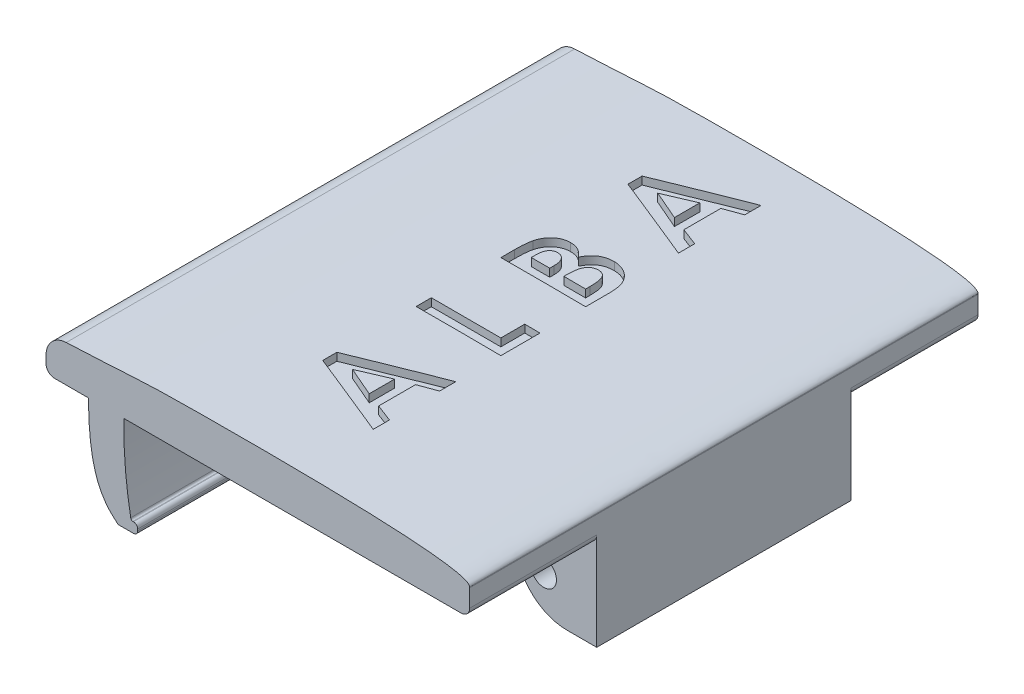
from build123d import *

# Parameters (mm, degrees)
BOSS_EXTRUDE1_DEPTH      = 12
SKETCH2_W                = 1.9
SKETCH2_H                = 6
BOSS_EXTRUDE2_DEPTH      = 2.1
BOSS_EXTRUDE2_DEPTH_BACK = 0.3
FILLET1_R                = 1.2
SKETCH3_R                = 0.3
CUT_EXTRUDE1_DEPTH       = 10.0000001
CUT_EXTRUDE3_DEPTH       = 0.3


with BuildPart() as part:
    # Sketch1 → Boss-Extrude1 (new body)
    with BuildSketch(Plane.XY):
        with BuildLine():
            Line((3.095772213, 5.384528852), (3.895772213, 5.384528852))
            add(Edge.make_bspline(
                [(3.895772213, 5.384528852), (3.903661021, 4.876234197), (3.940780884, 4.342027393), (4.23358721, 3.366561313), (4.591998935, 3.174137137), (4.595359051, 3.146585866)],
                knots=[0, 0, 0, 0, 0.345637442, 0.444282907, 0.986454656, 0.986454656, 0.986454656, 0.986454656], degree=3))
            Line((4.595359051, 3.146585866), (4.95987534, 3.146585866))
            ThreePointArc((4.95987534, 3.146585866), (5.030586018, 3.175875188), (5.05987534, 3.246585866))
            Line((5.05987534, 3.246585866), (5.05987534, 3.284528852))
            ThreePointArc((5.05987534, 3.284528852), (5.030586018, 3.35523953), (4.95987534, 3.384528852))
            Line((4.95987534, 3.384528852), (4.945772213, 3.384528852))
            ThreePointArc((4.945772213, 3.384528852), (4.910416874, 3.399173513), (4.895772213, 3.434528852))
            add(Edge.make_bspline(
                [(4.895772213, 3.434528852), (4.718180189, 4.396675532), (4.732797844, 5.384528852)],
                knots=[0, 0, 0, 1, 1, 1], degree=2))
            Line((4.732797844, 5.384528852), (4.895772213, 5.384528852))
            Line((4.895772213, 5.384528852), (12.695772213, 5.384528852))
            ThreePointArc((12.695772213, 5.384528852), (12.83719357, 5.443107495), (12.895772213, 5.584528852))
            Line((12.895772213, 5.584528852), (12.895772213, 6.001862294))
            ThreePointArc((12.895772213, 6.001862294), (12.895689546, 6.010954061), (12.895441572, 6.020042821))
            add(Edge.make_bspline(
                [(12.895441572, 6.020042821), (12.882423834, 6.377819315), (4.452086176, 6.40842871), (5.31917207, 6.339679785), (3.374260508, 6.255925505)],
                knots=[0.048294157, 0.048294157, 0.048294157, 0.048294157, 0.480381526, 0.960763051, 0.960763051, 0.960763051, 0.960763051], degree=3))
            ThreePointArc((3.374260508, 6.255925505), (3.034693377, 6.102252714), (2.895772213, 5.756388473))
            Line((2.895772213, 5.756388473), (2.895772213, 5.584528852))
            ThreePointArc((2.895772213, 5.584528852), (2.954350857, 5.443107495), (3.095772213, 5.384528852))
        make_face()
    extrude(amount=BOSS_EXTRUDE1_DEPTH)

    # Sketch2 → Boss-Extrude2 (add, two sides)
    with BuildSketch(Plane.XZ.offset(-5.384528852)) as boss_extrude2_sk:
        with Locations((11.945772213, 6)):
            Rectangle(SKETCH2_W, SKETCH2_H)
    extrude(amount=BOSS_EXTRUDE2_DEPTH)
    extrude(boss_extrude2_sk.sketch, amount=-BOSS_EXTRUDE2_DEPTH_BACK)

    # Fillet1
    fillet1_edges = [part.edges().sort_by_distance(p)[0] for p in [
        (10.995772213, 3.284528852, 6),
    ]]
    fillet(fillet1_edges, radius=FILLET1_R)

    # Sketch3 → Cut-Extrude1 (cut, through all)
    with BuildSketch(Plane.XY.offset(9)):
        with Locations((11.645772213, 4.184528852)):
            Circle(SKETCH3_R)
    extrude(amount=-CUT_EXTRUDE1_DEPTH, mode=Mode.SUBTRACT)

    # Sketch9 → Cut-Extrude3 (cut)
    with BuildSketch(Plane(origin=(0, 6.5, 0), x_dir=(-1, 0, 0), z_dir=(0, 1, 0))):
        Polygon((-6.895772213, 9.467821607), (-6.895772213, 9.134888915), (-8.895772213, 8.327196607), (-8.895772213, 8.710610069), (-8.485515803, 8.866058787), (-8.485515803, 9.737453018), (-8.895772213, 9.892901736), (-8.895772213, 10.275914556), align=None)
        Polygon((-7.432230547, 9.301555582), (-8.126541444, 9.601235069), (-8.126541444, 9.001876094), align=None, mode=Mode.SUBTRACT)
        Polygon((-6.895772213, 7.263094043), (-6.895772213, 6.904119684), (-8.536797854, 6.904119684), (-8.536797854, 6.34001712), (-8.895772213, 6.34001712), (-8.895772213, 7.263094043), align=None)
        with BuildLine():
            Line((-8.895772213, 5.263094043), (-6.895772213, 5.263094043))
            Line((-6.895772213, 5.263094043), (-6.895772213, 4.942581223))
            add(Edge.make_bspline(
                [(-6.895772213, 4.942581223), (-6.89576915, 4.920143281), (-6.895763223, 4.87672629), (-6.897969651, 4.81408755), (-6.900785983, 4.756126181), (-6.904042621, 4.702771449), (-6.909447398, 4.654043105), (-6.915263959, 4.609907591), (-6.922232029, 4.57052837), (-6.928486646, 4.546182634), (-6.931429265, 4.534728659)],
                knots=[0, 0, 0, 0, 6.7309e-05, 0.000130241, 0.000188002, 0.000241409, 0.000290564, 0.000335042, 0.000374962, 0.000410429, 0.000410429, 0.000410429, 0.000410429], degree=3))
            add(Edge.make_bspline(
                [(-6.931429265, 4.534728659), (-6.935579572, 4.519688397), (-6.943723806, 4.490174574), (-6.960171441, 4.447901364), (-6.97845415, 4.407799319), (-6.999311312, 4.36991744), (-7.022994683, 4.334488204), (-7.049692405, 4.301646744), (-7.078332148, 4.270682921), (-7.109714666, 4.242702918), (-7.142868572, 4.21739431), (-7.177819973, 4.195475979), (-7.213863307, 4.176197015), (-7.252000271, 4.161690241), (-7.29110813, 4.149383507), (-7.331937707, 4.141170522), (-7.374119089, 4.135654208), (-7.402831856, 4.135146589), (-7.417406829, 4.134888915)],
                knots=[0, 0, 0, 0, 4.6779e-05, 9.1795e-05, 0.000135895, 0.000178934, 0.000221381, 0.000263553, 0.000305788, 0.000347777, 0.000389524, 0.000430761, 0.00047144, 0.000511912, 0.000552974, 0.000594304, 0.000636692, 0.000680391, 0.000680391, 0.000680391, 0.000680391], degree=3))
            add(Edge.make_bspline(
                [(-7.417406829, 4.134888915), (-7.436140995, 4.135516162), (-7.473039023, 4.136751561), (-7.526999828, 4.146177564), (-7.578340947, 4.161543583), (-7.627551564, 4.182729904), (-7.674067743, 4.212006743), (-7.719345219, 4.247868191), (-7.762594053, 4.29196921), (-7.789098826, 4.325208854), (-7.802823495, 4.342420966)],
                knots=[0, 0, 0, 0, 5.6181e-05, 0.000110652, 0.000163762, 0.000216687, 0.000270834, 0.000328148, 0.000389624, 0.000455643, 0.000455643, 0.000455643, 0.000455643], degree=3))
            add(Edge.make_bspline(
                [(-7.802823495, 4.342420966), (-7.810021176, 4.328319243), (-7.824133835, 4.300669664), (-7.847343971, 4.261427485), (-7.871981315, 4.225048044), (-7.897833244, 4.191500729), (-7.925088509, 4.160902705), (-7.953875939, 4.133452902), (-7.983697761, 4.108578783), (-8.015161631, 4.086873499), (-8.047889868, 4.067949776), (-8.08193808, 4.051333271), (-8.117790231, 4.038024751), (-8.154686247, 4.026084094), (-8.193174336, 4.017333889), (-8.233120199, 4.011587026), (-8.274415685, 4.007199715), (-8.302544066, 4.006857689), (-8.316845931, 4.006683787)],
                knots=[0, 0, 0, 0, 4.7489e-05, 9.3113e-05, 0.000136672, 0.000179225, 0.000220083, 0.00025947, 0.000298456, 0.000336464, 0.000373983, 0.000411793, 0.000449963, 0.00048861, 0.000528068, 0.000568185, 0.000609645, 0.00065253, 0.00065253, 0.00065253, 0.00065253], degree=3))
            add(Edge.make_bspline(
                [(-8.316845931, 4.006683787), (-8.344175238, 4.007754958), (-8.398136694, 4.009869976), (-8.477072524, 4.026942267), (-8.552356588, 4.054339784), (-8.622879164, 4.092388221), (-8.687074775, 4.138980081), (-8.743313015, 4.192611572), (-8.790760662, 4.252634119), (-8.823070628, 4.307807267), (-8.844649453, 4.355757941), (-8.857809881, 4.395653107), (-8.8702541, 4.438396592), (-8.878905669, 4.484764398), (-8.886846605, 4.534002315), (-8.891744652, 4.586600667), (-8.895065437, 4.642458166), (-8.895531858, 4.680823635), (-8.895772213, 4.700594043)],
                knots=[0, 0, 0, 0, 8.1923e-05, 0.000161756, 0.000241099, 0.000321581, 0.000401318, 0.000478393, 0.000553979, 0.000630113, 0.000669572, 0.000711509, 0.000756031, 0.000803017, 0.00085288, 0.000905622, 0.000961403, 0.00102071, 0.00102071, 0.00102071, 0.00102071], degree=3))
            Line((-8.895772213, 4.700594043), (-8.895772213, 5.263094043))
        make_face()
        with BuildLine():
            Line((-7.254746572, 4.904119684), (-7.690644008, 4.904119684))
            Line((-7.690644008, 4.904119684), (-7.690644008, 4.80876712))
            add(Edge.make_bspline(
                [(-7.690644008, 4.80876712), (-7.690531513, 4.795807689), (-7.690314349, 4.770790292), (-7.687497647, 4.734657918), (-7.682727609, 4.701051252), (-7.675931061, 4.670014756), (-7.667695348, 4.64136713), (-7.657220309, 4.615447658), (-7.644721948, 4.592172173), (-7.626558815, 4.564747939), (-7.598744213, 4.536499336), (-7.559481892, 4.511204214), (-7.514037172, 4.496379474), (-7.48201799, 4.494720133), (-7.465483752, 4.493863274)],
                knots=[0, 0, 0, 0, 3.887e-05, 7.5037e-05, 0.000108636, 0.00014062, 0.000170283, 0.000197959, 0.000224307, 0.00024942, 0.000296451, 0.00034202, 0.000388391, 0.000437904, 0.000437904, 0.000437904, 0.000437904], degree=3))
            add(Edge.make_bspline(
                [(-7.465483752, 4.493863274), (-7.449995905, 4.494548676), (-7.420050777, 4.495873872), (-7.377975761, 4.510810639), (-7.340885044, 4.534079984), (-7.315125093, 4.561135675), (-7.297824625, 4.586940802), (-7.286230763, 4.609137003), (-7.276163259, 4.633633565), (-7.268199209, 4.660625987), (-7.262331286, 4.690016742), (-7.257998188, 4.721726971), (-7.255055537, 4.75582756), (-7.25485177, 4.779380218), (-7.254746572, 4.791539556)],
                knots=[0, 0, 0, 0, 4.6284e-05, 8.9488e-05, 0.000132169, 0.000176655, 0.000200323, 0.000225234, 0.000251646, 0.000279659, 0.000309517, 0.000341473, 0.000375643, 0.00041211, 0.00041211, 0.00041211, 0.00041211], degree=3))
            Line((-7.254746572, 4.791539556), (-7.254746572, 4.904119684))
        make_face(mode=Mode.SUBTRACT)
        with BuildLine():
            Line((-8.023977342, 4.904119684), (-8.536797854, 4.904119684))
            Line((-8.536797854, 4.904119684), (-8.536797854, 4.8007543))
            add(Edge.make_bspline(
                [(-8.536797854, 4.8007543), (-8.536681107, 4.780318831), (-8.536456646, 4.741029094), (-8.533744626, 4.684746615), (-8.528856687, 4.63357177), (-8.522754489, 4.587640155), (-8.514486966, 4.546881415), (-8.503975869, 4.511433326), (-8.492411831, 4.480809763), (-8.478128872, 4.455194346), (-8.46150705, 4.434268018), (-8.444519148, 4.415384201), (-8.424921998, 4.399987513), (-8.403556851, 4.387805366), (-8.380954434, 4.37726174), (-8.356232129, 4.370902569), (-8.330122648, 4.366060919), (-8.312063284, 4.36579447), (-8.302823495, 4.365658146)],
                knots=[0, 0, 0, 0, 6.1303e-05, 0.000117863, 0.000168971, 0.000215489, 0.000256819, 0.000293582, 0.000326317, 0.000354842, 0.000381126, 0.000406353, 0.000430881, 0.00045548, 0.00048005, 0.000505421, 0.000531833, 0.000559503, 0.000559503, 0.000559503, 0.000559503], degree=3))
            add(Edge.make_bspline(
                [(-8.302823495, 4.365658146), (-8.29225762, 4.365958748), (-8.271678136, 4.366544241), (-8.24159957, 4.37132692), (-8.213517158, 4.38001618), (-8.186722614, 4.390968682), (-8.16213939, 4.406179435), (-8.139129249, 4.424308884), (-8.11784783, 4.445768011), (-8.097931884, 4.470400026), (-8.080187567, 4.499138013), (-8.065148812, 4.532180137), (-8.052273288, 4.569335463), (-8.042150222, 4.610831054), (-8.033528004, 4.656527697), (-8.028386934, 4.706780851), (-8.024560725, 4.761165356), (-8.024176221, 4.798876751), (-8.023977342, 4.818382505)],
                knots=[0, 0, 0, 0, 3.1691e-05, 6.1726e-05, 9.1006e-05, 0.000119729, 0.000148313, 0.000177408, 0.000207437, 0.000238785, 0.00027225, 0.000308458, 0.000347483, 0.000390044, 0.000436485, 0.000486879, 0.000541485, 0.000599991, 0.000599991, 0.000599991, 0.000599991], degree=3))
            Line((-8.023977342, 4.818382505), (-8.023977342, 4.904119684))
        make_face(mode=Mode.SUBTRACT)
        Polygon((-6.895772213, 2.262693402), (-6.895772213, 1.92976071), (-8.895772213, 1.122068402), (-8.895772213, 1.505481864), (-8.485515803, 1.660930582), (-8.485515803, 2.532324812), (-8.895772213, 2.68777353), (-8.895772213, 3.070786351), align=None)
        Polygon((-7.432230547, 2.096427377), (-8.126541444, 2.396106864), (-8.126541444, 1.796747889), align=None, mode=Mode.SUBTRACT)
    extrude(amount=-CUT_EXTRUDE3_DEPTH, mode=Mode.SUBTRACT)


solid = part.part
